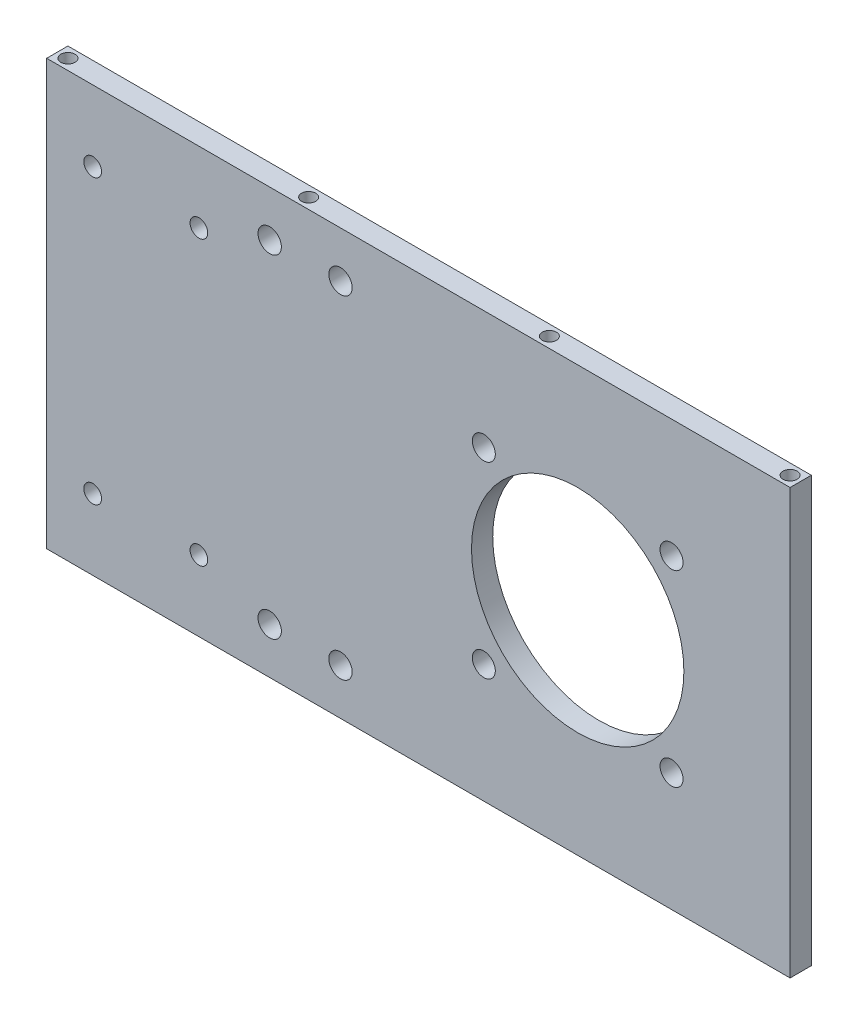
from build123d import *

# Parameters (mm, degrees)
SKETCH_1_W          = 210
SKETCH_1_H          = 120
SKETCH_1_R          = 3.25
SKETCH_1_R_2        = 30
EXTRUDE_1_DEPTH     = 6
SKETCH_2_R          = 2.5
CUT_EXTRUDE_1_DEPTH = 10
SKETCH_3_R          = 2
CUT_EXTRUDE_2_DEPTH = 20
SKETCH_4_R          = 3.3
CUT_EXTRUDE_3_DEPTH = 10


with BuildPart() as part:
    # 草图1 → 凸台-拉伸1 (new body)
    with BuildSketch(Plane.XY):
        with Locations((-45, 0)):
            Rectangle(SKETCH_1_W, SKETCH_1_H)
        with Locations((26.516504294, 26.516504294)):
            Circle(SKETCH_1_R, mode=Mode.SUBTRACT)
        with Locations((26.516504294, -26.516504294)):
            Circle(SKETCH_1_R, mode=Mode.SUBTRACT)
        with Locations((-26.516504294, -26.516504294)):
            Circle(SKETCH_1_R, mode=Mode.SUBTRACT)
        with Locations((-26.516504294, 26.516504294)):
            Circle(SKETCH_1_R, mode=Mode.SUBTRACT)
        Circle(SKETCH_1_R_2, mode=Mode.SUBTRACT)
    extrude(amount=EXTRUDE_1_DEPTH)

    # 草图2 → 切除-拉伸1 (cut)
    with BuildSketch(Plane.XY.offset(6)):
        with Locations((-137, 40)):
            Circle(SKETCH_2_R)
        with Locations((-107, 40)):
            Circle(SKETCH_2_R)
        with Locations((-107, -40)):
            Circle(SKETCH_2_R)
        with Locations((-137, -40)):
            Circle(SKETCH_2_R)
    extrude(amount=-CUT_EXTRUDE_1_DEPTH, mode=Mode.SUBTRACT)

    # 草图3 → 切除-拉伸2 (cut)
    with BuildSketch(Plane(origin=(0, -60, 0), x_dir=(-1, 0, 0), z_dir=(0, -1, 0))):
        with Locations((-57, -3)):
            Circle(SKETCH_3_R)
        with Locations((11, -3)):
            Circle(SKETCH_3_R)
        with Locations((79, -3)):
            Circle(SKETCH_3_R)
        with Locations((147, -3)):
            Circle(SKETCH_3_R)
    cut_extrude_2 = extrude(amount=-CUT_EXTRUDE_2_DEPTH, mode=Mode.SUBTRACT)

    # 镜向3: 切除-拉伸2 across plane
    add(cut_extrude_2.mirror(Plane(origin=(0, 0, 0), x_dir=(0, 0, 1), z_dir=(0, -1, 0))), mode=Mode.SUBTRACT)

    # 草图4 → 切除-拉伸3 (cut)
    with BuildSketch(Plane.XY.offset(6)):
        with Locations((-87, 47)):
            Circle(SKETCH_4_R)
        with Locations((-67, 47)):
            Circle(SKETCH_4_R)
        with Locations((-67, -47)):
            Circle(SKETCH_4_R)
        with Locations((-87, -47)):
            Circle(SKETCH_4_R)
    extrude(amount=-CUT_EXTRUDE_3_DEPTH, mode=Mode.SUBTRACT)


solid = part.part
